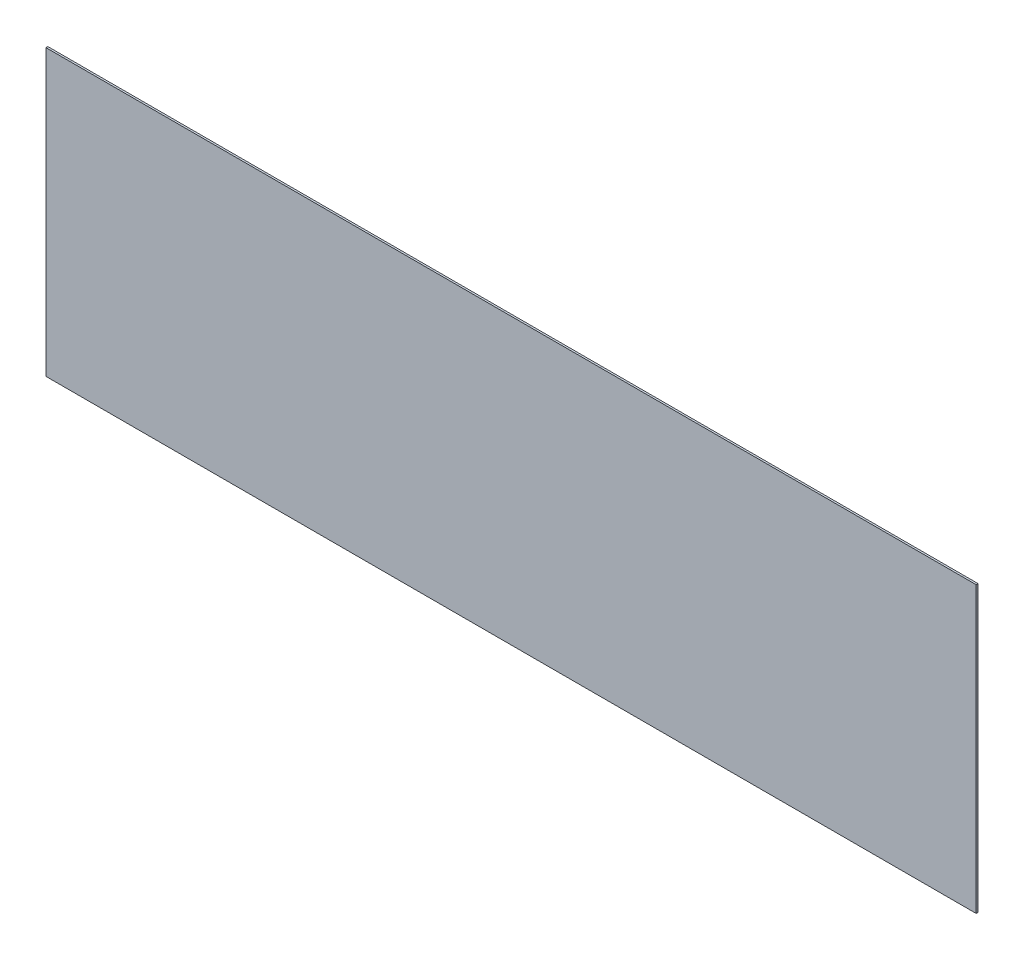
from build123d import *

# Parameters (mm, degrees)
SKETCH1_W           = 49
SKETCH1_H           = 15
BOSS_EXTRUDE1_DEPTH = 0.1


with BuildPart() as part:
    # Sketch1 → Boss-Extrude1 (new body)
    with BuildSketch(Plane.XY):
        with Locations((1.62022726, 3.696236559)):
            Rectangle(SKETCH1_W, SKETCH1_H)
    extrude(amount=BOSS_EXTRUDE1_DEPTH)


solid = part.part
